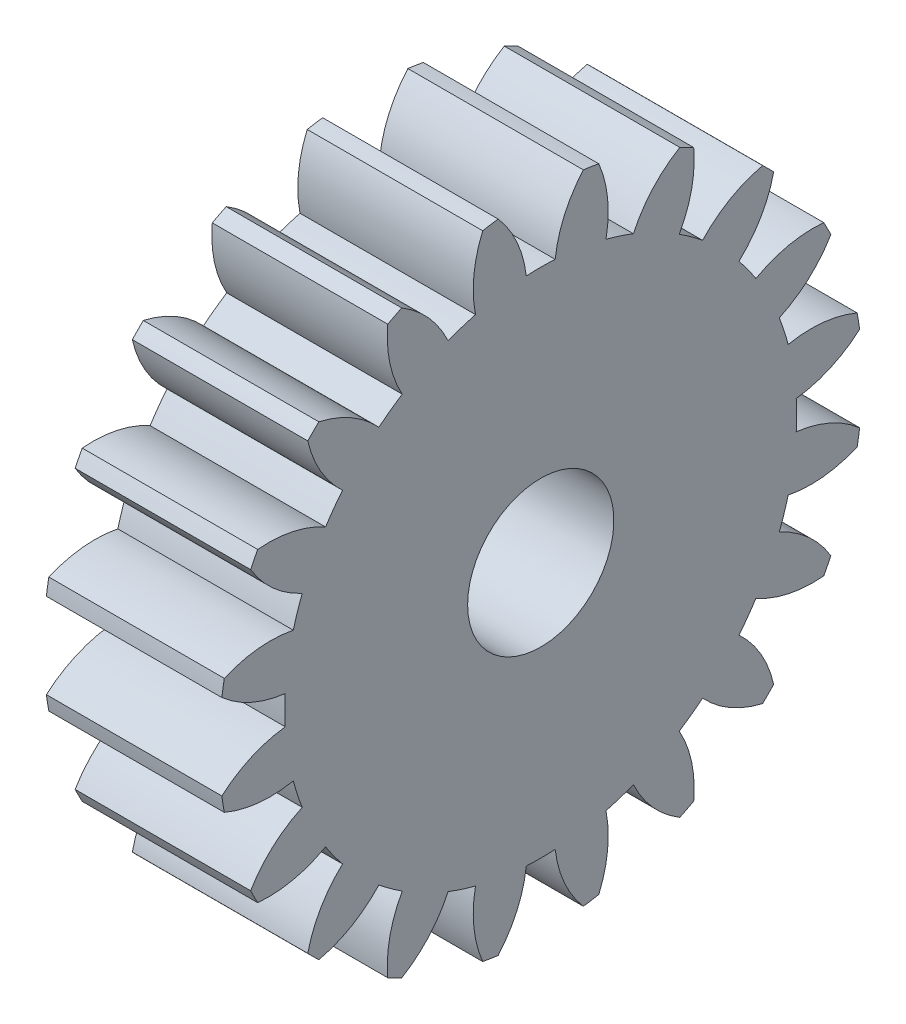
from build123d import *

# Parameters (mm, degrees)
BASPROSKE_W     = 12
BASPROSKE_H     = 22
TOOTHCUT_DEPTH  = 34.346664001
TEETHCUTS_COUNT = 20
TEETHCUTS_ANGLE = 342
BORSKE_R        = 5
BORE_DEPTH      = 50.0000508


with BuildPart() as part:
    # BasProSke → Base-Revolve (revolve)
    with BuildSketch(Plane(origin=(0, 0, 0), x_dir=(1, 0, 0), z_dir=(0, 1, 0)), mode=Mode.PRIVATE) as base_revolve_sk:
        with Locations((6, 11)):
            Rectangle(BASPROSKE_W, BASPROSKE_H)
    revolve(base_revolve_sk.sketch.rotate(Axis((-10, 0, 0), (1, 0, 0)), 180), axis=Axis((-10, 0, 0), (1, 0, 0)))

    # TooCutSke → ToothCut (cut, through all)
    with BuildSketch(Plane(origin=(0, 0, 0), x_dir=(0, 0, -1), z_dir=(1, 0, 0))):
        with BuildLine():
            ThreePointArc((0.986171591, 17.471189616), (0, 17.499), (-0.986171591, 17.471189616))
            ThreePointArc((-0.986171591, 17.471189616), (-1.626916196, 19.798789858), (-2.932850173, 21.829260982))
            ThreePointArc((-2.932850173, 21.829260982), (0, 22.0254), (2.932850173, 21.829260982))
            ThreePointArc((2.932850173, 21.829260982), (1.626916196, 19.798789858), (0.986171591, 17.471189616))
        make_face()
    toothcut = extrude(amount=TOOTHCUT_DEPTH, mode=Mode.SUBTRACT)

    # TeethCuts: ToothCut ×20 about axis
    teethcuts_axis = Axis((-10, 0, 0), (1, 0, 0))
    for i in range(1, TEETHCUTS_COUNT):
        add(toothcut.rotate(teethcuts_axis, i * TEETHCUTS_ANGLE / (TEETHCUTS_COUNT - 1)), mode=Mode.SUBTRACT)

    # BorSke → Bore (cut, symmetric)
    with BuildSketch(Plane(origin=(0, 0, 0), x_dir=(0, 0, -1), z_dir=(1, 0, 0))):
        with Locations(Location((0, 0, 0), (0, 0, 180))):
            Circle(BORSKE_R)
    extrude(amount=BORE_DEPTH, both=True, mode=Mode.SUBTRACT)


solid = part.part
